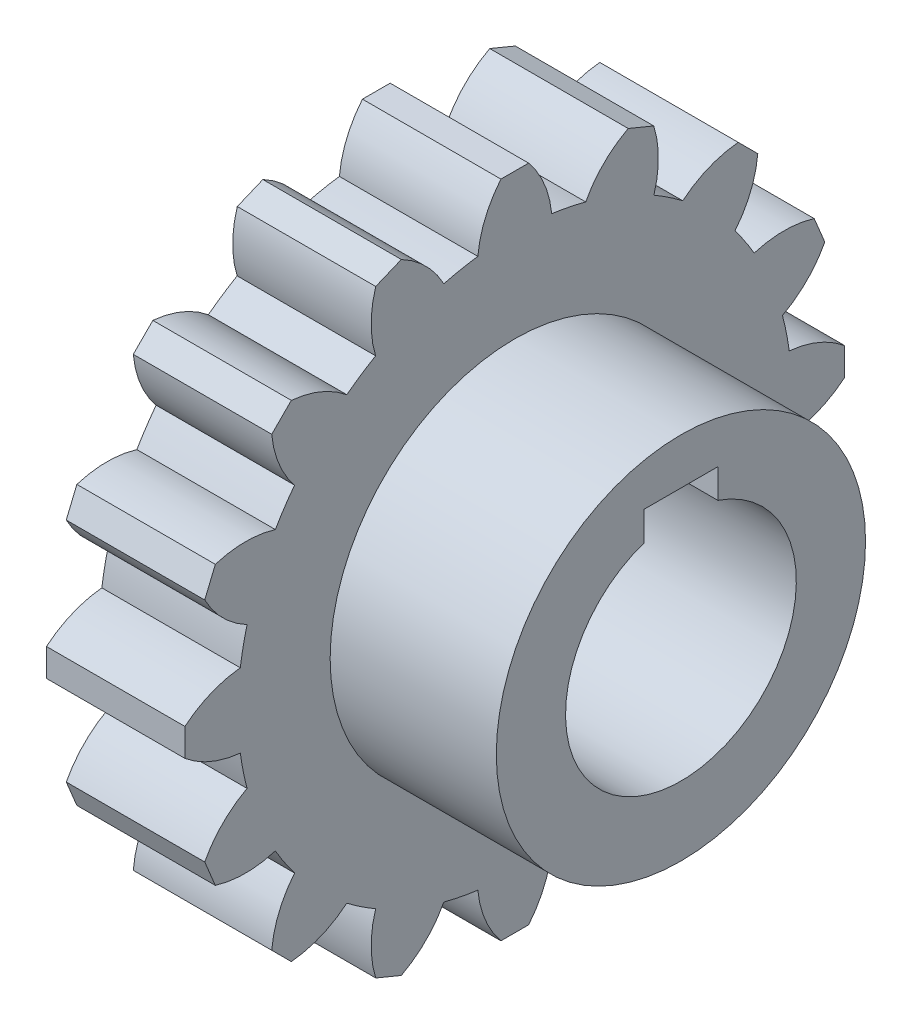
from build123d import *

# Parameters (mm, degrees)
SKETCH1_R           = 30
BOSS_EXTRUDE1_DEPTH = 7.5
BOSS_EXTRUDE2_DEPTH = 15
CIRPATTERN1_COUNT   = 16
SKETCH3_R           = 20
BOSS_EXTRUDE3_DEPTH = 18
CUT_EXTRUDE1_DEPTH  = 44


with BuildPart() as part:
    # Sketch1 → Boss-Extrude1 (new body, symmetric)
    with BuildSketch(Plane(origin=(0, 0, 0), x_dir=(0, 0, -1), z_dir=(1, 0, 0))):
        Circle(SKETCH1_R)
    extrude(amount=BOSS_EXTRUDE1_DEPTH, both=True)

    # Sketch2 → Boss-Extrude2 (add, through all)
    with BuildSketch(Plane(origin=(7.5, 0, 0), x_dir=(0, 0, -1), z_dir=(1, 0, 0))):
        with BuildLine():
            Line((-1.5, 35.732137495), (1.5, 35.732137495))
            ThreePointArc((1.5, 35.732137495), (3.203300204, 32.92101258), (4, 29.732137495))
            ThreePointArc((4, 29.732137495), (0, 30), (-4, 29.732137495))
            ThreePointArc((-4, 29.732137495), (-3.203300204, 32.92101258), (-1.5, 35.732137495))
        make_face()
    boss_extrude2 = extrude(amount=-BOSS_EXTRUDE2_DEPTH)

    # CirPattern1: Boss-Extrude2 ×16 about axis
    cirpattern1_axis = Axis((0, 0, 0), (1, 0, 0))
    for i in range(1, CIRPATTERN1_COUNT):
        add(boss_extrude2.rotate(cirpattern1_axis, i * 360 / CIRPATTERN1_COUNT))

    # Sketch3 → Boss-Extrude3 (add, symmetric)
    with BuildSketch(Plane(origin=(7.5, 0, 0), x_dir=(0, 0, -1), z_dir=(1, 0, 0))):
        Circle(SKETCH3_R)
    extrude(amount=BOSS_EXTRUDE3_DEPTH, both=True)

    # Sketch4 → Cut-Extrude1 (cut)
    with BuildSketch(Plane(origin=(25.5, 0, 0), x_dir=(0, 0, -1), z_dir=(1, 0, 0))):
        with BuildLine():
            Line((-4, 15), (4, 15))
            Line((4, 15), (4, 11.842719282))
            ThreePointArc((4, 11.842719282), (0, -12.5), (-4, 11.842719282))
            Line((-4, 11.842719282), (-4, 15))
        make_face()
    extrude(amount=-CUT_EXTRUDE1_DEPTH, mode=Mode.SUBTRACT)


solid = part.part
